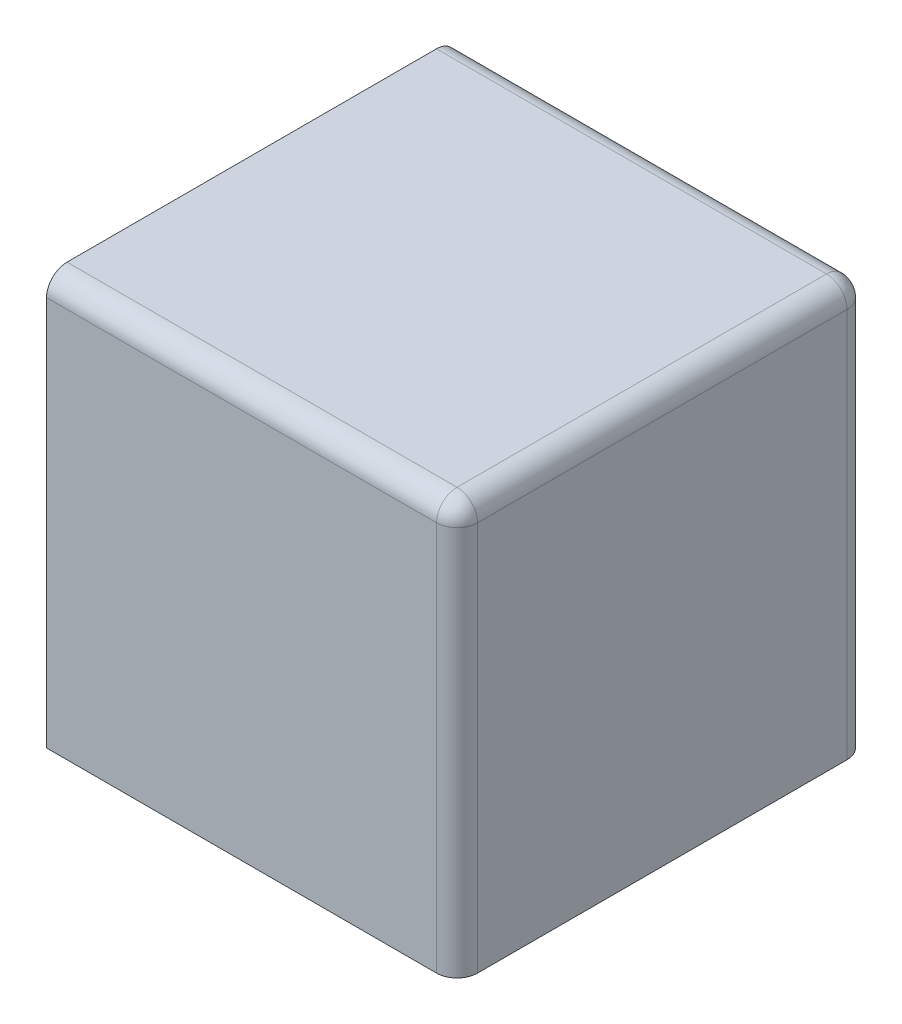
from build123d import *

# Parameters (mm, degrees)
SKETCH1_W           = 20
SKETCH1_H           = 20
BOSS_EXTRUDE1_DEPTH = 20
SKETCH2_R           = 2.5
BOSS_EXTRUDE2_DEPTH = 6
FILLET1_R           = 1


with BuildPart() as part:
    # Sketch1 → Boss-Extrude1 (new body)
    with BuildSketch(Plane(origin=(0, 0, 0), x_dir=(1, 0, 0), z_dir=(0, 1, 0))):
        Rectangle(SKETCH1_W, SKETCH1_H)
    extrude(amount=BOSS_EXTRUDE1_DEPTH)

    # Sketch2 → Boss-Extrude2 (add)
    with BuildSketch(Plane.ZY.offset(10)):
        with Locations((0, 10)):
            Circle(SKETCH2_R)
    extrude(amount=BOSS_EXTRUDE2_DEPTH)

    # Fillet1
    fillet1_edges = [part.edges().sort_by_distance(p)[0] for p in [
        (10, 20, 0),
        (0, 20, -10),
        (10, 10, -10),
        (10, 10, 10),
        (0, 20, 10),
    ]]
    fillet(fillet1_edges, radius=FILLET1_R)


solid = part.part
